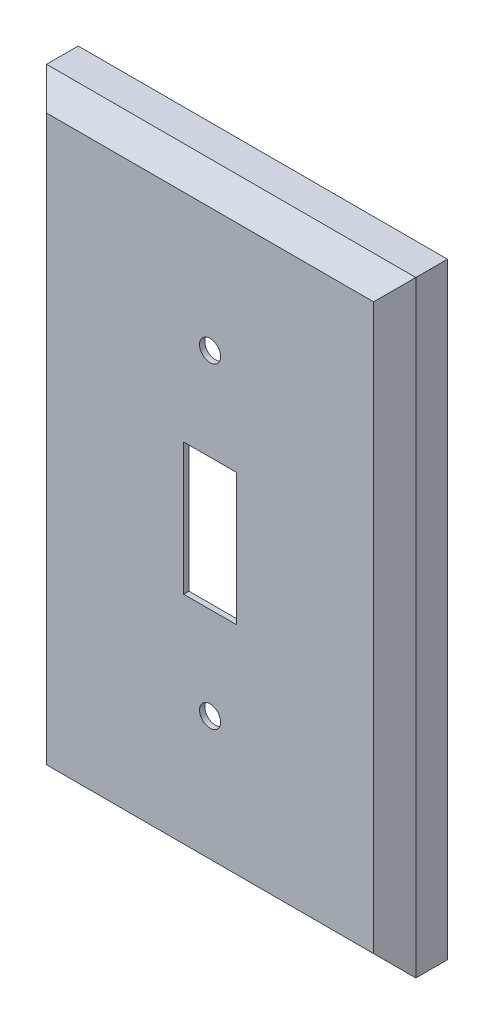
from build123d import *

# Parameters (mm, degrees)
SKICA1_W                 = 70
SKICA1_H                 = 115
VYSUNOUT1_DEPTH          = 10
ZKOSIT1_SIZE             = 4
SKO_EPINA1_T             = -1
SKICA3_R                 = 2
SKICA3_W                 = 10
SKICA3_H                 = 25
ODEBRAT_VYSUNUT_M1_DEPTH = 11


with BuildPart() as part:
    # Skica1 → Vysunout1 (new body)
    with BuildSketch(Plane.XY):
        with Locations((35, 57.5)):
            Rectangle(SKICA1_W, SKICA1_H)
    extrude(amount=VYSUNOUT1_DEPTH)

    # Zkosit1
    zkosit1_edges = [part.edges().sort_by_distance(p)[0] for p in [
        (70, 57.5, 10),
        (35, 115, 10),
        (0, 57.5, 10),
        (35, 0, 10),
    ]]
    chamfer(zkosit1_edges, length=ZKOSIT1_SIZE)

    # Skořepina1
    sko_epina1_openings = [part.faces().sort_by_distance(p)[0] for p in [
        (35, 57.5, 0),
    ]]
    offset(amount=SKO_EPINA1_T, openings=sko_epina1_openings, kind=Kind.INTERSECTION)

    # Skica3 → Odebrat vysunutím1 (cut, through all)
    with BuildSketch(Plane.XY.offset(10)):
        with Locations((35, 87.5)):
            Circle(SKICA3_R)
        with Locations((35, 27.5)):
            Circle(SKICA3_R)
        with Locations((35, 57.5)):
            Rectangle(SKICA3_W, SKICA3_H)
    extrude(amount=-ODEBRAT_VYSUNUT_M1_DEPTH, mode=Mode.SUBTRACT)


solid = part.part
